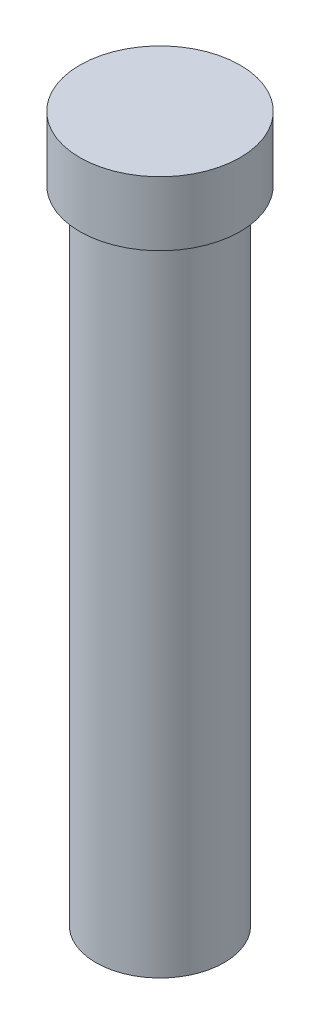
from build123d import *

# Parameters (mm, degrees)
SKETCH1_R           = 2
BOSS_EXTRUDE1_DEPTH = 20
SKETCH2_R           = 2.5
BOSS_EXTRUDE2_DEPTH = 2


with BuildPart() as part:
    # Sketch1 → Boss-Extrude1 (new body)
    with BuildSketch(Plane(origin=(0, 0, 0), x_dir=(1, 0, 0), z_dir=(0, 1, 0))):
        Circle(SKETCH1_R)
    extrude(amount=BOSS_EXTRUDE1_DEPTH)

    # Sketch2 → Boss-Extrude2 (add)
    with BuildSketch(Plane(origin=(0, 20, 0), x_dir=(1, 0, 0), z_dir=(0, 1, 0))):
        Circle(SKETCH2_R)
    extrude(amount=BOSS_EXTRUDE2_DEPTH)


solid = part.part
